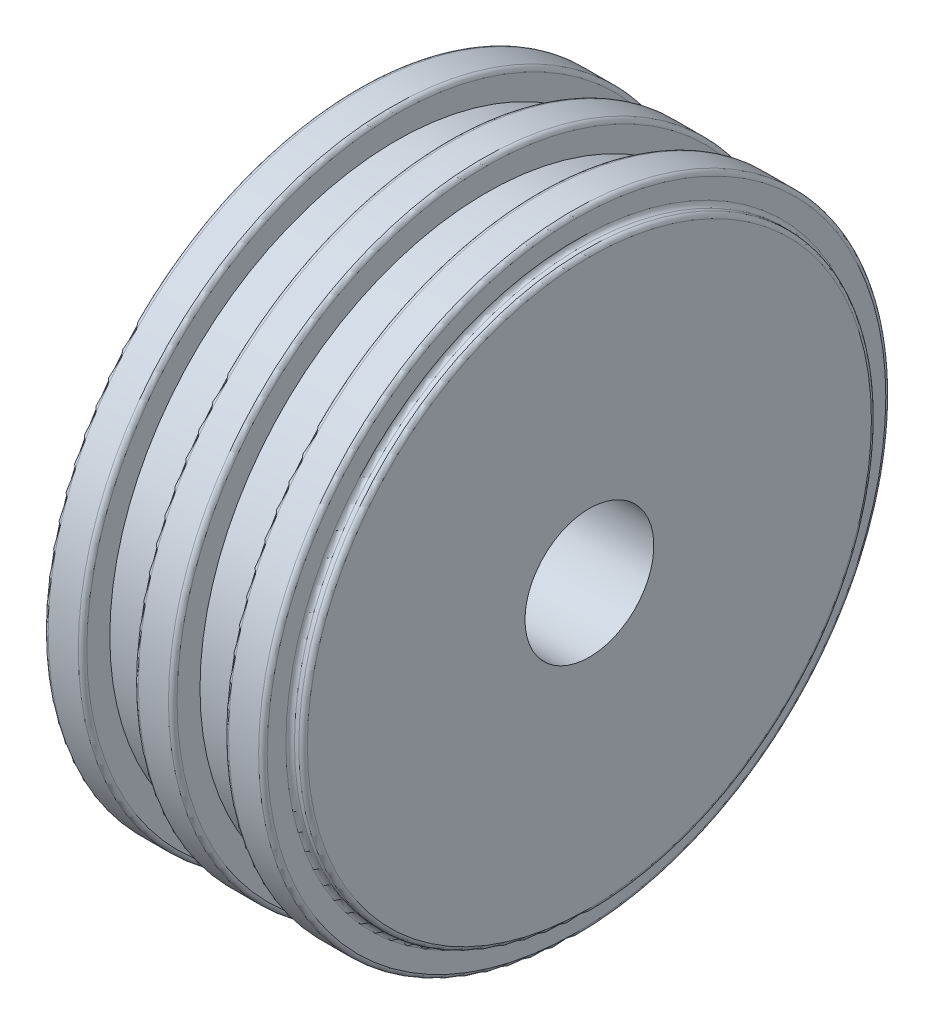
from build123d import *

# Parameters (mm, degrees)
FILLET1_R = 1


with BuildPart() as part:
    # Sketch1 → Revolve1 (revolve)
    with BuildSketch(Plane.XY):
        Polygon((0, 15), (0, 66.675), (-3, 66.675), (-3, 73.025), (-12, 73.025), (-12, 66.675), (-24, 66.675), (-24, 73.025), (-33, 73.025), (-33, 66.675), (-45, 66.675), (-45, 73.025), (-54, 73.025), (-54, 66.675), (-57, 66.675), (-57, 15), align=None)
    revolve(axis=Axis((-513.282786888, 0, 0), (1, 0, 0)))

    # Fillet1
    fillet1_edges = [part.edges().sort_by_distance(p)[0] for p in [
        (-57, -66.675, 0),
        (-54, -66.675, 0),
        (-54, -73.025, 0),
        (-45, -73.025, 0),
        (-33, -73.025, 0),
        (-24, -73.025, 0),
        (-12, -73.025, 0),
        (-3, -73.025, 0),
        (-3, -66.675, 0),
        (0, -66.675, 0),
    ]]
    fillet(fillet1_edges, radius=FILLET1_R)


solid = part.part
